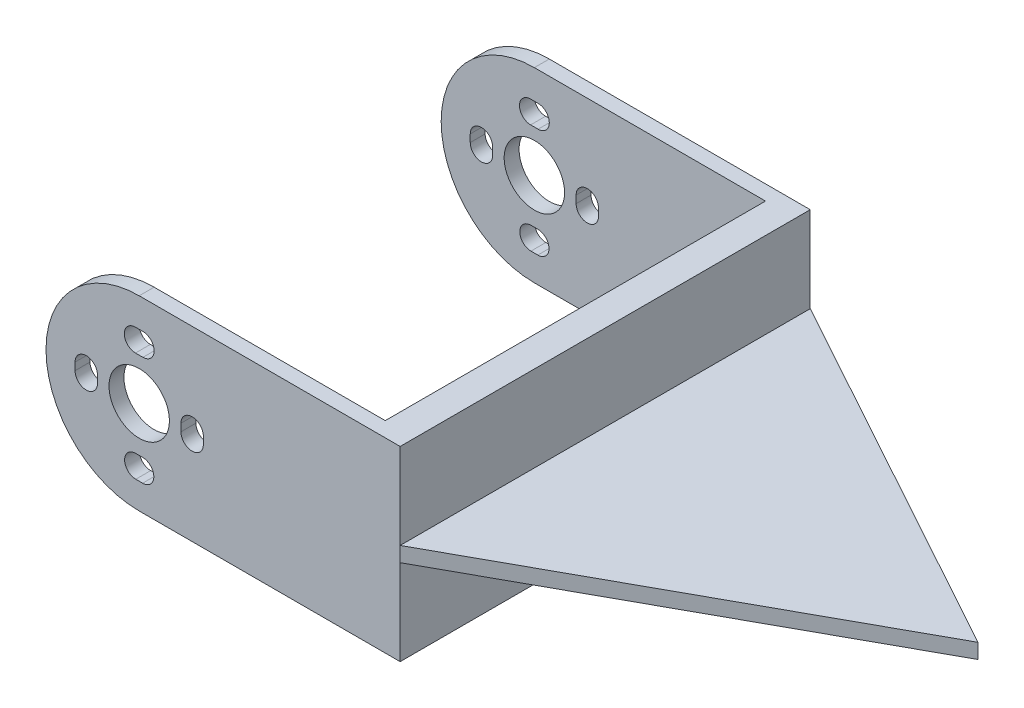
from build123d import *

# Parameters (mm, degrees)
SKETCH1_W           = 62
SKETCH1_H           = 42
SKETCH1_W_2         = 41
SKETCH1_H_2         = 21
BOSS_EXTRUDE1_DEPTH = 42
SKETCH2_W           = 4
SKETCH2_H           = 25
BOSS_EXTRUDE2_DEPTH = 4.5
SKETCH2_2_W         = 4
SKETCH2_2_H         = 25
BOSS_EXTRUDE3_DEPTH = 45.55
SKETCH3_R           = 4.05
BOSS_EXTRUDE6_DEPTH = 2
BOSS_EXTRUDE7_START = -53
SKETCH3_8_R         = 4.05
BOSS_EXTRUDE7_DEPTH = 53
CUT_EXTRUDE1_START  = -51
SKETCH3_11_R        = 4.05
CUT_EXTRUDE1_DEPTH  = 51
SKETCH_1_W          = 8.5
SKETCH_1_H          = 5.5
CUT_EXTRUDE_1_DEPTH = 40
CUT_EXTRUDE_3_DEPTH = 42
EXTRUDE_1_DEPTH     = 13.5
CUT_EXTRUDE_4_DEPTH = 11.5


with BuildPart() as part:
    # Sketch1 → Boss-Extrude1 (new body)
    with BuildSketch(Plane.XY):
        with Locations((1.904162196, -4.136072895)):
            Rectangle(SKETCH1_W, SKETCH1_H)
        with Locations((1.904162196, -4.136072895)):
            Rectangle(SKETCH1_W_2, SKETCH1_H_2, mode=Mode.SUBTRACT)
    extrude(amount=BOSS_EXTRUDE1_DEPTH)

    # Sketch2 → Boss-Extrude2 (add)
    with BuildSketch(Plane.XY.offset(42)):
        with Locations((-27.095837804, -4.136072895)):
            Rectangle(SKETCH2_W, SKETCH2_H)
    extrude(amount=BOSS_EXTRUDE2_DEPTH)

    # Sketch2_2 → Boss-Extrude3 (add)
    with BuildSketch(Plane.XY.offset(42)):
        with Locations((-27.095837804, -4.136072895)):
            Rectangle(SKETCH2_2_W, SKETCH2_2_H)
    extrude(amount=-BOSS_EXTRUDE3_DEPTH)

    # Sketch3 → Boss-Extrude6 (add)
    with BuildSketch(Plane.XY.offset(46.5)):
        with BuildLine():
            Line((-25.095837804, -16.636072895), (-25.095837804, 8.363927105))
            Line((-25.095837804, 8.363927105), (-60.095837804, 8.363927105))
            ThreePointArc((-60.095837804, 8.363927105), (-72.595837804, -4.136072895), (-60.095837804, -16.636072895))
            Line((-60.095837804, -16.636072895), (-25.095837804, -16.636072895))
        make_face()
        with BuildLine():
            Line((-51.495837804, -3.636072895), (-51.495837804, -4.636072895))
            ThreePointArc((-51.495837804, -4.636072895), (-52.995837804, -6.136072895), (-54.495837804, -4.636072895))
            Line((-54.495837804, -4.636072895), (-54.495837804, -3.636072895))
            ThreePointArc((-54.495837804, -3.636072895), (-52.995837804, -2.136072895), (-51.495837804, -3.636072895))
        make_face(mode=Mode.SUBTRACT)
        with BuildLine():
            Line((-59.635749439, -13.176248856), (-60.555926168, -13.176248856))
            ThreePointArc((-60.555926168, -13.176248856), (-62.055926168, -11.676248856), (-60.555926168, -10.176248856))
            Line((-60.555926168, -10.176248856), (-59.635749439, -10.176248856))
            ThreePointArc((-59.635749439, -10.176248856), (-58.135749439, -11.676248856), (-59.635749439, -13.176248856))
        make_face(mode=Mode.SUBTRACT)
        with Locations((-60.095837804, -4.136072895)):
            Circle(SKETCH3_R, mode=Mode.SUBTRACT)
        with BuildLine():
            Line((-59.595837804, 1.463927105), (-60.595837804, 1.463927105))
            ThreePointArc((-60.595837804, 1.463927105), (-62.095837804, 2.963927105), (-60.595837804, 4.463927105))
            Line((-60.595837804, 4.463927105), (-59.595837804, 4.463927105))
            ThreePointArc((-59.595837804, 4.463927105), (-58.095837804, 2.963927105), (-59.595837804, 1.463927105))
        make_face(mode=Mode.SUBTRACT)
        with BuildLine():
            ThreePointArc((-68.695837804, -3.636072895), (-67.195837804, -2.136072895), (-65.695837804, -3.636072895))
            Line((-65.695837804, -3.636072895), (-65.695837804, -4.636072895))
            ThreePointArc((-65.695837804, -4.636072895), (-67.195837804, -6.136072895), (-68.695837804, -4.636072895))
            Line((-68.695837804, -4.636072895), (-68.695837804, -3.636072895))
        make_face(mode=Mode.SUBTRACT)
    extrude(amount=BOSS_EXTRUDE6_DEPTH)

    # Sketch3_8 → Boss-Extrude7 (add)
    with BuildSketch(Plane.XY.offset(46.5).offset(BOSS_EXTRUDE7_START)):
        with BuildLine():
            Line((-25.095837804, -16.636072895), (-25.095837804, 8.363927105))
            Line((-25.095837804, 8.363927105), (-60.095837804, 8.363927105))
            ThreePointArc((-60.095837804, 8.363927105), (-72.595837804, -4.136072895), (-60.095837804, -16.636072895))
            Line((-60.095837804, -16.636072895), (-25.095837804, -16.636072895))
        make_face()
        with BuildLine():
            Line((-51.495837804, -3.636072895), (-51.495837804, -4.636072895))
            ThreePointArc((-51.495837804, -4.636072895), (-52.995837804, -6.136072895), (-54.495837804, -4.636072895))
            Line((-54.495837804, -4.636072895), (-54.495837804, -3.636072895))
            ThreePointArc((-54.495837804, -3.636072895), (-52.995837804, -2.136072895), (-51.495837804, -3.636072895))
        make_face(mode=Mode.SUBTRACT)
        with BuildLine():
            Line((-59.635749439, -13.176248856), (-60.555926168, -13.176248856))
            ThreePointArc((-60.555926168, -13.176248856), (-62.055926168, -11.676248856), (-60.555926168, -10.176248856))
            Line((-60.555926168, -10.176248856), (-59.635749439, -10.176248856))
            ThreePointArc((-59.635749439, -10.176248856), (-58.135749439, -11.676248856), (-59.635749439, -13.176248856))
        make_face(mode=Mode.SUBTRACT)
        with Locations((-60.095837804, -4.136072895)):
            Circle(SKETCH3_8_R, mode=Mode.SUBTRACT)
        with BuildLine():
            Line((-59.595837804, 1.463927105), (-60.595837804, 1.463927105))
            ThreePointArc((-60.595837804, 1.463927105), (-62.095837804, 2.963927105), (-60.595837804, 4.463927105))
            Line((-60.595837804, 4.463927105), (-59.595837804, 4.463927105))
            ThreePointArc((-59.595837804, 4.463927105), (-58.095837804, 2.963927105), (-59.595837804, 1.463927105))
        make_face(mode=Mode.SUBTRACT)
        with BuildLine():
            ThreePointArc((-68.695837804, -3.636072895), (-67.195837804, -2.136072895), (-65.695837804, -3.636072895))
            Line((-65.695837804, -3.636072895), (-65.695837804, -4.636072895))
            ThreePointArc((-65.695837804, -4.636072895), (-67.195837804, -6.136072895), (-68.695837804, -4.636072895))
            Line((-68.695837804, -4.636072895), (-68.695837804, -3.636072895))
        make_face(mode=Mode.SUBTRACT)
    extrude(amount=BOSS_EXTRUDE7_DEPTH)

    # Sketch3_11 → Cut-Extrude1 (cut)
    with BuildSketch(Plane.XY.offset(46.5).offset(CUT_EXTRUDE1_START)):
        with BuildLine():
            Line((-29.095837804, -16.636072895), (-29.095837804, 8.363927105))
            Line((-29.095837804, 8.363927105), (-60.095837804, 8.363927105))
            ThreePointArc((-60.095837804, 8.363927105), (-72.595837804, -4.136072895), (-60.095837804, -16.636072895))
            Line((-60.095837804, -16.636072895), (-29.095837804, -16.636072895))
        make_face()
        with BuildLine():
            Line((-59.635749439, -13.176248856), (-60.555926168, -13.176248856))
            ThreePointArc((-60.555926168, -13.176248856), (-62.055926168, -11.676248856), (-60.555926168, -10.176248856))
            Line((-60.555926168, -10.176248856), (-59.635749439, -10.176248856))
            ThreePointArc((-59.635749439, -10.176248856), (-58.135749439, -11.676248856), (-59.635749439, -13.176248856))
        make_face(mode=Mode.SUBTRACT)
        with Locations((-60.095837804, -4.136072895)):
            Circle(SKETCH3_11_R, mode=Mode.SUBTRACT)
        with BuildLine():
            Line((-59.595837804, 1.463927105), (-60.595837804, 1.463927105))
            ThreePointArc((-60.595837804, 1.463927105), (-62.095837804, 2.963927105), (-60.595837804, 4.463927105))
            Line((-60.595837804, 4.463927105), (-59.595837804, 4.463927105))
            ThreePointArc((-59.595837804, 4.463927105), (-58.095837804, 2.963927105), (-59.595837804, 1.463927105))
        make_face(mode=Mode.SUBTRACT)
        with BuildLine():
            ThreePointArc((-54.495837804, -3.636072895), (-52.995837804, -2.136072895), (-51.495837804, -3.636072895))
            Line((-51.495837804, -3.636072895), (-51.495837804, -4.636072895))
            ThreePointArc((-51.495837804, -4.636072895), (-52.995837804, -6.136072895), (-54.495837804, -4.636072895))
            Line((-54.495837804, -4.636072895), (-54.495837804, -3.636072895))
        make_face(mode=Mode.SUBTRACT)
        with BuildLine():
            ThreePointArc((-68.695837804, -3.636072895), (-67.195837804, -2.136072895), (-65.695837804, -3.636072895))
            Line((-65.695837804, -3.636072895), (-65.695837804, -4.636072895))
            ThreePointArc((-65.695837804, -4.636072895), (-67.195837804, -6.136072895), (-68.695837804, -4.636072895))
            Line((-68.695837804, -4.636072895), (-68.695837804, -3.636072895))
        make_face(mode=Mode.SUBTRACT)
    extrude(amount=CUT_EXTRUDE1_DEPTH, mode=Mode.SUBTRACT)

    # 草圖1 → 除料-伸長1 (cut)
    with BuildSketch(Plane(origin=(0, 16.863927105, 0), x_dir=(1, 0, 0), z_dir=(0, 1, 0))):
        with Locations((8.454162196, -32.5)):
            Rectangle(SKETCH_1_W, SKETCH_1_H)
    extrude(amount=-CUT_EXTRUDE_1_DEPTH, mode=Mode.SUBTRACT)

    # 草圖3 → 除料-伸長3 (cut)
    with BuildSketch(Plane(origin=(0, 0, 0), x_dir=(-1, 0, 0), z_dir=(0, 0, -1))):
        Polygon((29.095837804, 8.363927105), (29.095837804, 16.863927105), (-32.904162196, 16.863927105), (-32.904162196, -25.136072895), (29.095837804, -25.136072895), (29.095837804, -16.636072895), (25.095837804, -16.636072895), (25.095837804, 8.363927105), align=None)
    extrude(amount=-CUT_EXTRUDE_3_DEPTH, mode=Mode.SUBTRACT)

    # 草圖5 → 填料-伸長1 (add)
    with BuildSketch(Plane(origin=(0, 8.363927105, 0), x_dir=(1, 0, 0), z_dir=(0, 1, 0))):
        Polygon((-25.095837804, 6.5), (-25.095837804, -48.5), (24.904162196, -21), align=None)
    extrude(amount=-EXTRUDE_1_DEPTH)

    # 草圖5<2> → 除料-伸長4 (cut)
    with BuildSketch(Plane(origin=(0, 8.363927105, 0), x_dir=(1, 0, 0), z_dir=(0, 1, 0))):
        Polygon((-25.095837804, 6.5), (-25.095837804, -48.5), (24.904162196, -21), align=None)
    extrude(amount=-CUT_EXTRUDE_4_DEPTH, mode=Mode.SUBTRACT)


solid = part.part
